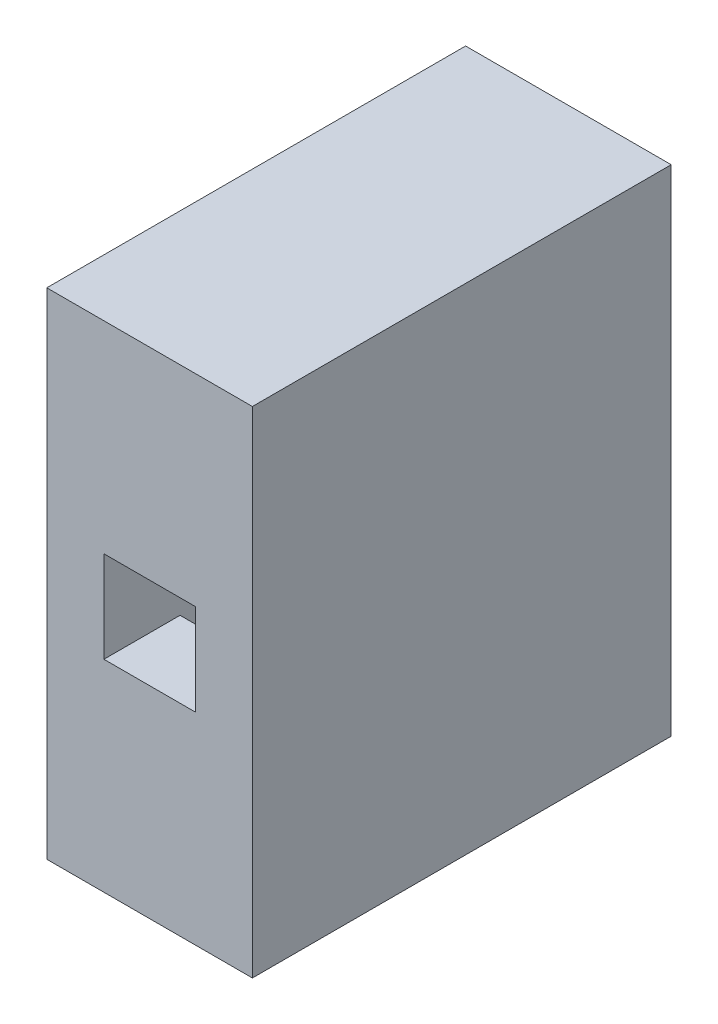
from build123d import *

# Parameters (mm, degrees)
SKETCH1_W           = 10.8
SKETCH1_H           = 26
SKETCH1_W_2         = 4.8
SKETCH1_H_2         = 20
BOSS_EXTRUDE1_DEPTH = 18
SKETCH2_W           = 10.8
SKETCH2_H           = 26
SKETCH2_W_2         = 4.8
SKETCH2_H_2         = 4.8
BOSS_EXTRUDE2_DEPTH = 4


with BuildPart() as part:
    # Sketch1 → Boss-Extrude1 (new body)
    with BuildSketch(Plane.XY):
        Rectangle(SKETCH1_W, SKETCH1_H)
        Rectangle(SKETCH1_W_2, SKETCH1_H_2, mode=Mode.SUBTRACT)
    extrude(amount=BOSS_EXTRUDE1_DEPTH)

    # Sketch2 → Boss-Extrude2 (add)
    with BuildSketch(Plane.XY.offset(18)):
        Rectangle(SKETCH2_W, SKETCH2_H)
        Rectangle(SKETCH2_W_2, SKETCH2_H_2, mode=Mode.SUBTRACT)
    extrude(amount=BOSS_EXTRUDE2_DEPTH)


solid = part.part
